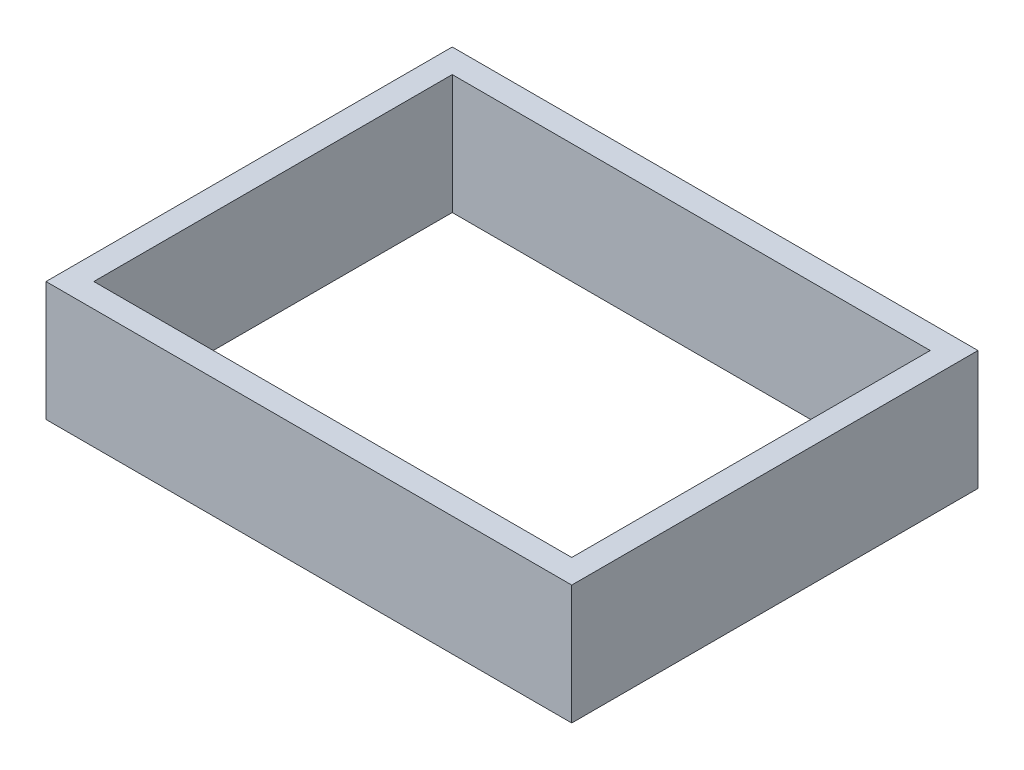
from build123d import *

# Parameters (mm, degrees)
SKETCH_1_W      = 44
SKETCH_1_H      = 34
SKETCH_1_W_2    = 40
SKETCH_1_H_2    = 30
EXTRUDE_1_DEPTH = 10


with BuildPart() as part:
    # 草图1 → 凸台-拉伸1 (new body)
    with BuildSketch(Plane(origin=(0, 0, 0), x_dir=(1, 0, 0), z_dir=(0, 1, 0))):
        Rectangle(SKETCH_1_W, SKETCH_1_H)
        Rectangle(SKETCH_1_W_2, SKETCH_1_H_2, mode=Mode.SUBTRACT)
    extrude(amount=EXTRUDE_1_DEPTH)


solid = part.part
